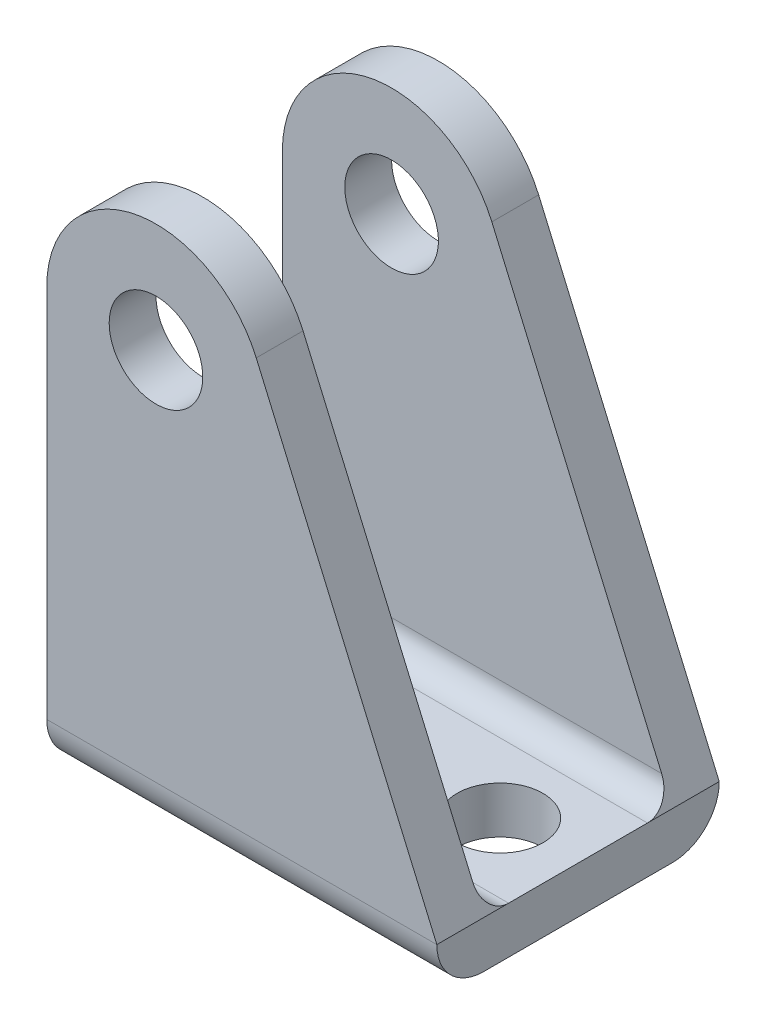
from build123d import *

# Parameters (mm, degrees)
BOSS_EXTRUDE1_DEPTH      = 25
BOSS_EXTRUDE1_DEPTH_BACK = 25
CUT_EXTRUDE1_DEPTH       = 25
CUT_EXTRUDE1_DEPTH_BACK  = 25
SKETCH2_W                = 74.2
SKETCH2_H                = 66.1
CUT_EXTRUDE2_DEPTH       = 12.1
CUT_EXTRUDE2_DEPTH_BACK  = 12.1
SKETCH3_R                = 3
CUT_EXTRUDE3_DEPTH       = 3
CUT_EXTRUDE3_DEPTH_BACK  = 3
SKETCH4_R                = 2.75
CUT_EXTRUDE4_DEPTH       = 3
CUT_EXTRUDE4_DEPTH_BACK  = 3
SKETCH5_R                = 2.75


with BuildPart() as part:
    # Sketch1 → Boss-Extrude1 (new, two sides: drawn at the far end of the back side and taken through both)
    with BuildSketch(Plane(origin=(0, 0, 0), x_dir=(0, 0, -1), z_dir=(1, 0, 0)).offset(-BOSS_EXTRUDE1_DEPTH_BACK)):
        with BuildLine():
            Line((-6.05, 0), (6.05, 0))
            ThreePointArc((6.05, 0), (8.171320344, 0.878679656), (9.05, 3))
            Line((9.05, 3), (9.05, 34))
            Line((9.05, 34), (6.05, 34))
            Line((6.05, 34), (6.05, 4.6))
            ThreePointArc((6.05, 4.6), (5.58137085, 3.46862915), (4.45, 3))
            Line((4.45, 3), (-4.45, 3))
            ThreePointArc((-4.45, 3), (-5.58137085, 3.46862915), (-6.05, 4.6))
            Line((-6.05, 4.6), (-6.05, 34))
            Line((-6.05, 34), (-9.05, 34))
            Line((-9.05, 34), (-9.05, 3))
            ThreePointArc((-9.05, 3), (-8.171320344, 0.878679656), (-6.05, 0))
        make_face()
    extrude(amount=BOSS_EXTRUDE1_DEPTH + BOSS_EXTRUDE1_DEPTH_BACK)

    # Sketch2 → Cut-Extrude1 (cut, two sides: drawn at the far end of the back side and taken through both)
    with BuildSketch(Plane.XY.offset(-CUT_EXTRUDE1_DEPTH_BACK)):
        with Locations((0, 20.95)):
            Rectangle(SKETCH2_W, SKETCH2_H)
        with BuildLine():
            Line((0, 0), (25, 0))
            Line((25, 0), (25, 3))
            Line((25, 3), (13.425422134, 29.777399934))
            ThreePointArc((13.425422134, 29.777399934), (5.58189474, 33.854850653), (0, 27))
            Line((0, 27), (0, 0))
        make_face(mode=Mode.SUBTRACT)
    extrude(amount=CUT_EXTRUDE1_DEPTH + CUT_EXTRUDE1_DEPTH_BACK, mode=Mode.SUBTRACT)

    # Sketch3 → Cut-Extrude2 (cut, two sides: drawn at the far end of the back side and taken through both)
    with BuildSketch(Plane.XY.offset(-CUT_EXTRUDE2_DEPTH_BACK)):
        with Locations((7, 27)):
            Circle(SKETCH3_R)
    extrude(amount=CUT_EXTRUDE2_DEPTH + CUT_EXTRUDE2_DEPTH_BACK, mode=Mode.SUBTRACT)

    # Sketch4 → Cut-Extrude3 (cut, two sides: drawn at the far end of the back side and taken through both)
    with BuildSketch(Plane(origin=(0, 0, 0), x_dir=(1, 0, 0), z_dir=(0, 1, 0)).offset(-CUT_EXTRUDE3_DEPTH_BACK)):
        with Locations((5, 0)):
            Circle(SKETCH4_R)
    extrude(amount=CUT_EXTRUDE3_DEPTH + CUT_EXTRUDE3_DEPTH_BACK, mode=Mode.SUBTRACT)

    # Sketch5 → Cut-Extrude4 (cut, two sides: drawn at the far end of the back side and taken through both)
    with BuildSketch(Plane(origin=(0, 0, 0), x_dir=(1, 0, 0), z_dir=(0, 1, 0)).offset(-CUT_EXTRUDE4_DEPTH_BACK)):
        with Locations((20, 0)):
            Circle(SKETCH5_R)
    extrude(amount=CUT_EXTRUDE4_DEPTH + CUT_EXTRUDE4_DEPTH_BACK, mode=Mode.SUBTRACT)


solid = part.part
